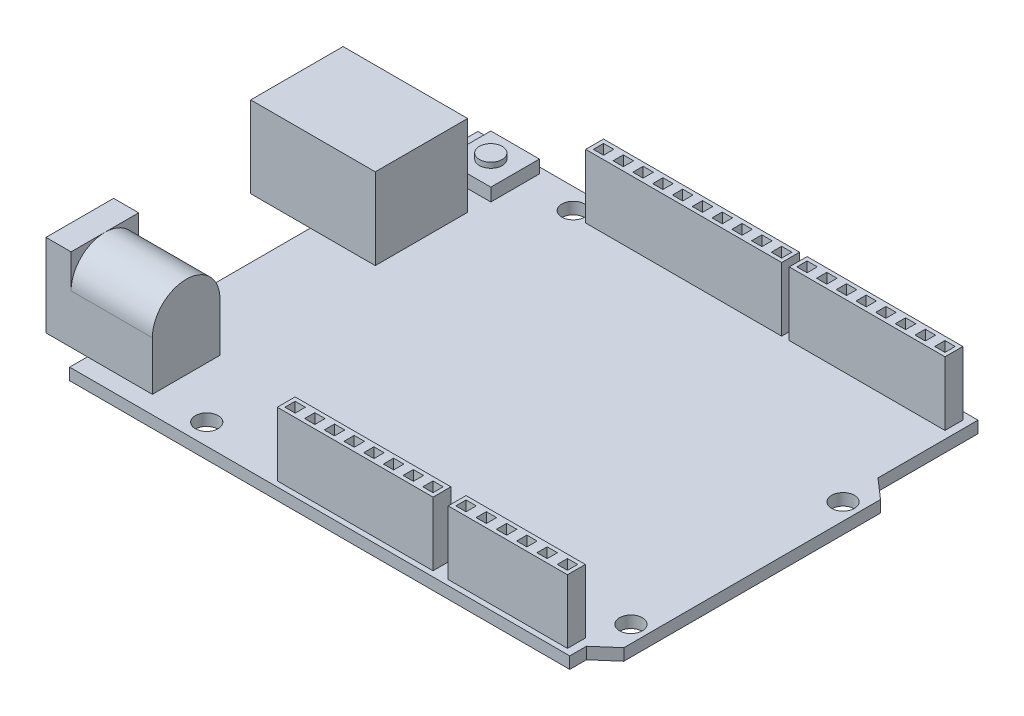
from build123d import *

# Parameters (mm, degrees)
RESSALTO_EXTRUS_O1_DEPTH   = 0.775
ESBO_O2_W                  = 16.4
ESBO_O2_H                  = 12.16
RESSALTO_EXTRUS_O2_DEPTH   = 10.7
ESBO_O3_W                  = 6.4
ESBO_O3_H                  = 6.4
RESSALTO_EXTRUS_O3_DEPTH   = 1.7
ESBO_O4_R                  = 1.5
RESSALTO_EXTRUS_O4_DEPTH   = 0.7
ESBO_O5_W                  = 14
ESBO_O5_H                  = 8.9
RESSALTO_EXTRUS_O5_DEPTH   = 10.9
CORTE_EXTRUS_O1_DEPTH      = 10.7
ESBO_O7_W                  = 25.8
ESBO_O7_H                  = 2.35
RESSALTO_EXTRUS_O6_DEPTH   = 8.4
ESBO_O7_W_2                = 20.5
RESSALTO_EXTRUS_O6_2_DEPTH = 8.4
RESSALTO_EXTRUS_O6_3_DEPTH = 8.4
ESBO_O7_W_3                = 15.7
RESSALTO_EXTRUS_O6_4_DEPTH = 8.4
ESBO_O8_R                  = 1.5
CORTE_EXTRUS_O2_DEPTH      = 1
CORTE_EXTRUS_O2_DEPTH_BACK = 13.45
ESBO_O9_W                  = 1.35
ESBO_O9_H                  = 1.35
CORTE_EXTRUS_O3_DEPTH      = 5
CORTE_EXTRUS_O3_TAPER      = 5


with BuildPart() as part:
    # Esboço1 → Ressalto-extrusão1 (new body, symmetric)
    with BuildSketch(Plane(origin=(0, 0, 0), x_dir=(1, 0, 0), z_dir=(0, 1, 0))):
        Polygon((-32.92, 26.875), (32.92, 26.875), (32.92, 13.705), (35.55, 11.410833485), (35.55, -22.380833485), (32.92, -24.675), (32.92, -26.875), (-32.92, -26.875), align=None)
    extrude(amount=RESSALTO_EXTRUS_O1_DEPTH, both=True)

    # Esboço2 → Ressalto-extrusão2 (add)
    with BuildSketch(Plane(origin=(0, 0.775, 0), x_dir=(1, 0, 0), z_dir=(0, 1, 0))):
        with Locations((-32.57, 10.895)):
            Rectangle(ESBO_O2_W, ESBO_O2_H)
    extrude(amount=RESSALTO_EXTRUS_O2_DEPTH)

    # Esboço3 → Ressalto-extrusão3 (add)
    with BuildSketch(Plane(origin=(0, 0.775, 0), x_dir=(1, 0, 0), z_dir=(0, 1, 0))):
        with Locations((-27.22, 22.875)):
            Rectangle(ESBO_O3_W, ESBO_O3_H)
    extrude(amount=RESSALTO_EXTRUS_O3_DEPTH)

    # Esboço8 → Corte-extrusão2 (cut, two sides)
    with BuildSketch(Plane.XZ.offset(0.775)) as corte_extrus_o2_sk:
        with Locations((-17.62, 24.125)):
            Circle(ESBO_O8_R)
        with Locations((-17.62, -24.125)):
            Circle(ESBO_O8_R)
        with Locations((33.35, -8.675)):
            Circle(ESBO_O8_R)
        with Locations((33.35, 19.245)):
            Circle(ESBO_O8_R)
    extrude(amount=CORTE_EXTRUS_O2_DEPTH, mode=Mode.SUBTRACT)
    extrude(corte_extrus_o2_sk.sketch, amount=-CORTE_EXTRUS_O2_DEPTH_BACK, mode=Mode.SUBTRACT)


with BuildPart() as body_2:
    # Esboço4 → Ressalto-extrusão4 (new body)
    with BuildSketch(Plane(origin=(0, 2.475, 0), x_dir=(1, 0, 0), z_dir=(0, 1, 0))):
        with Locations((-27.22, 22.875)):
            Circle(ESBO_O4_R)
    extrude(amount=RESSALTO_EXTRUS_O4_DEPTH)


with BuildPart() as body_3:
    # Esboço5 → Ressalto-extrusão5 (new body)
    with BuildSketch(Plane(origin=(0, 0.775, 0), x_dir=(1, 0, 0), z_dir=(0, 1, 0))):
        with Locations((-31.37, -20.085)):
            Rectangle(ESBO_O5_W, ESBO_O5_H)
    extrude(amount=RESSALTO_EXTRUS_O5_DEPTH)

    # Esboço6 → Corte-extrusão1 (cut)
    with BuildSketch(Plane(origin=(-24.37, 0, 0), x_dir=(0, 0, -1), z_dir=(1, 0, 0))):
        with BuildLine():
            Line((-24.535, 7.225), (-25.535, 7.225))
            Line((-25.535, 7.225), (-25.535, 12.675))
            Line((-25.535, 12.675), (-14.635, 12.675))
            Line((-14.635, 12.675), (-14.635, 7.225))
            Line((-14.635, 7.225), (-15.635, 7.225))
            ThreePointArc((-15.635, 7.225), (-20.085, 11.675), (-24.535, 7.225))
        make_face()
    extrude(amount=-CORTE_EXTRUS_O1_DEPTH, mode=Mode.SUBTRACT)


with BuildPart() as body_4:
    # Esboço7 → Ressalto-extrusão6 (new body)
    with BuildSketch(Plane(origin=(0, 0.775, 0), x_dir=(1, 0, 0), z_dir=(0, 1, 0))):
        with Locations((-2.48, 24.7)):
            Rectangle(ESBO_O7_W, ESBO_O7_H)
    extrude(amount=RESSALTO_EXTRUS_O6_DEPTH)


with BuildPart() as body_5:
    # Esboço7 → Ressalto-extrus_o6 2 (new body)
    with BuildSketch(Plane(origin=(0, 0.775, 0), x_dir=(1, 0, 0), z_dir=(0, 1, 0))):
        with Locations((21.67, 24.7)):
            Rectangle(ESBO_O7_W_2, ESBO_O7_H)
    extrude(amount=RESSALTO_EXTRUS_O6_2_DEPTH)


with BuildPart() as body_6:
    # Esboço7 → Ressalto-extrus_o6 3 (new body)
    with BuildSketch(Plane(origin=(0, 0.775, 0), x_dir=(1, 0, 0), z_dir=(0, 1, 0))):
        with Locations((3.97, -25)):
            Rectangle(ESBO_O7_W_2, ESBO_O7_H)
    extrude(amount=RESSALTO_EXTRUS_O6_3_DEPTH)


with BuildPart() as body_7:
    # Esboço7 → Ressalto-extrus_o6 4 (new body)
    with BuildSketch(Plane(origin=(0, 0.775, 0), x_dir=(1, 0, 0), z_dir=(0, 1, 0))):
        with Locations((24.07, -25)):
            Rectangle(ESBO_O7_W_3, ESBO_O7_H)
    extrude(amount=RESSALTO_EXTRUS_O6_4_DEPTH)


with BuildPart() as corte_extrus_o3_tool:
    # Esboço9 → Corte-extrusão3 (new body)
    with BuildSketch(Plane(origin=(0, 9.175, 0), x_dir=(1, 0, 0), z_dir=(0, 1, 0))):
        with Locations((-14.205, 24.7)):
            Rectangle(ESBO_O9_W, ESBO_O9_H)
        with Locations((-11.599444444, 24.7)):
            Rectangle(ESBO_O9_W, ESBO_O9_H)
        with Locations((-8.993888889, 24.7)):
            Rectangle(ESBO_O9_W, ESBO_O9_H)
        with Locations((-6.388333333, 24.7)):
            Rectangle(ESBO_O9_W, ESBO_O9_H)
        with Locations((-3.782777778, 24.7)):
            Rectangle(ESBO_O9_W, ESBO_O9_H)
        with Locations((-1.177222222, 24.7)):
            Rectangle(ESBO_O9_W, ESBO_O9_H)
        with Locations((1.428333333, 24.7)):
            Rectangle(ESBO_O9_W, ESBO_O9_H)
        with Locations((4.033888889, 24.7)):
            Rectangle(ESBO_O9_W, ESBO_O9_H)
        with Locations((6.639444444, 24.7)):
            Rectangle(ESBO_O9_W, ESBO_O9_H)
        with Locations((9.245, 24.7)):
            Rectangle(ESBO_O9_W, ESBO_O9_H)
        with Locations((12.595, 24.7)):
            Rectangle(ESBO_O9_W, ESBO_O9_H)
        with Locations((-5.105, -25)):
            Rectangle(ESBO_O9_W, ESBO_O9_H)
        with Locations((17.395, -25)):
            Rectangle(ESBO_O9_W, ESBO_O9_H)
        with Locations((15.187857143, 24.7)):
            Rectangle(ESBO_O9_W, ESBO_O9_H)
        with Locations((17.780714286, 24.7)):
            Rectangle(ESBO_O9_W, ESBO_O9_H)
        with Locations((20.373571429, 24.7)):
            Rectangle(ESBO_O9_W, ESBO_O9_H)
        with Locations((22.966428571, 24.7)):
            Rectangle(ESBO_O9_W, ESBO_O9_H)
        with Locations((25.559285714, 24.7)):
            Rectangle(ESBO_O9_W, ESBO_O9_H)
        with Locations((28.152142857, 24.7)):
            Rectangle(ESBO_O9_W, ESBO_O9_H)
        with Locations((30.745, 24.7)):
            Rectangle(ESBO_O9_W, ESBO_O9_H)
        with Locations((-2.512142857, -25)):
            Rectangle(ESBO_O9_W, ESBO_O9_H)
        with Locations((0.080714286, -25)):
            Rectangle(ESBO_O9_W, ESBO_O9_H)
        with Locations((2.673571429, -25)):
            Rectangle(ESBO_O9_W, ESBO_O9_H)
        with Locations((5.266428571, -25)):
            Rectangle(ESBO_O9_W, ESBO_O9_H)
        with Locations((7.859285714, -25)):
            Rectangle(ESBO_O9_W, ESBO_O9_H)
        with Locations((10.452142857, -25)):
            Rectangle(ESBO_O9_W, ESBO_O9_H)
        with Locations((13.045, -25)):
            Rectangle(ESBO_O9_W, ESBO_O9_H)
        with Locations((20.065, -25)):
            Rectangle(ESBO_O9_W, ESBO_O9_H)
        with Locations((22.735, -25)):
            Rectangle(ESBO_O9_W, ESBO_O9_H)
        with Locations((25.405, -25)):
            Rectangle(ESBO_O9_W, ESBO_O9_H)
        with Locations((28.075, -25)):
            Rectangle(ESBO_O9_W, ESBO_O9_H)
        with Locations((30.745, -25)):
            Rectangle(ESBO_O9_W, ESBO_O9_H)
    extrude(amount=-CORTE_EXTRUS_O3_DEPTH, taper=CORTE_EXTRUS_O3_TAPER)


with BuildPart() as body_4_1:
    add(body_4.part)

    # Corte-extrusão3: cut by corte_extrus_o3_tool
    add(corte_extrus_o3_tool.part, mode=Mode.SUBTRACT)


with BuildPart() as body_5_1:
    add(body_5.part)

    # Corte-extrusão3: cut by corte_extrus_o3_tool
    add(corte_extrus_o3_tool.part, mode=Mode.SUBTRACT)


with BuildPart() as body_6_1:
    add(body_6.part)

    # Corte-extrusão3: cut by corte_extrus_o3_tool
    add(corte_extrus_o3_tool.part, mode=Mode.SUBTRACT)


with BuildPart() as body_7_1:
    add(body_7.part)

    # Corte-extrusão3: cut by corte_extrus_o3_tool
    add(corte_extrus_o3_tool.part, mode=Mode.SUBTRACT)


solid = Compound([part.part, body_2.part, body_3.part, body_4_1.part, body_5_1.part, body_6_1.part, body_7_1.part])
